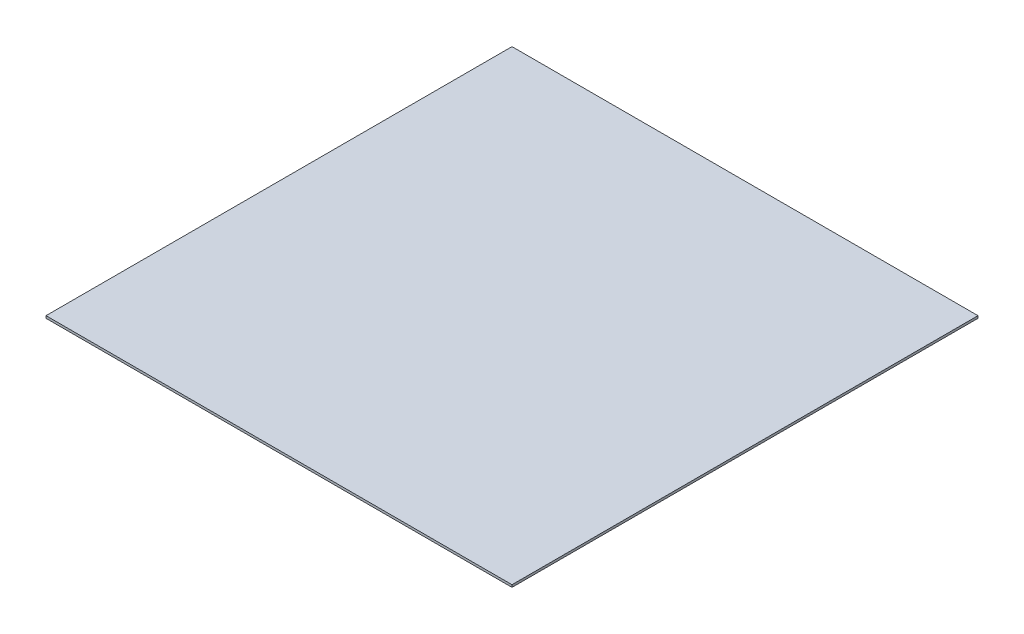
from build123d import *

# Parameters (mm, degrees)
SKETCH_1_W      = 200
SKETCH_1_H      = 200
EXTRUDE_1_DEPTH = 1


with BuildPart() as part:
    # 草图1 → 凸台-拉伸1 (new body)
    with BuildSketch(Plane(origin=(0, 0, 0), x_dir=(1, 0, 0), z_dir=(0, 1, 0))):
        Rectangle(SKETCH_1_W, SKETCH_1_H)
    extrude(amount=EXTRUDE_1_DEPTH)


solid = part.part
